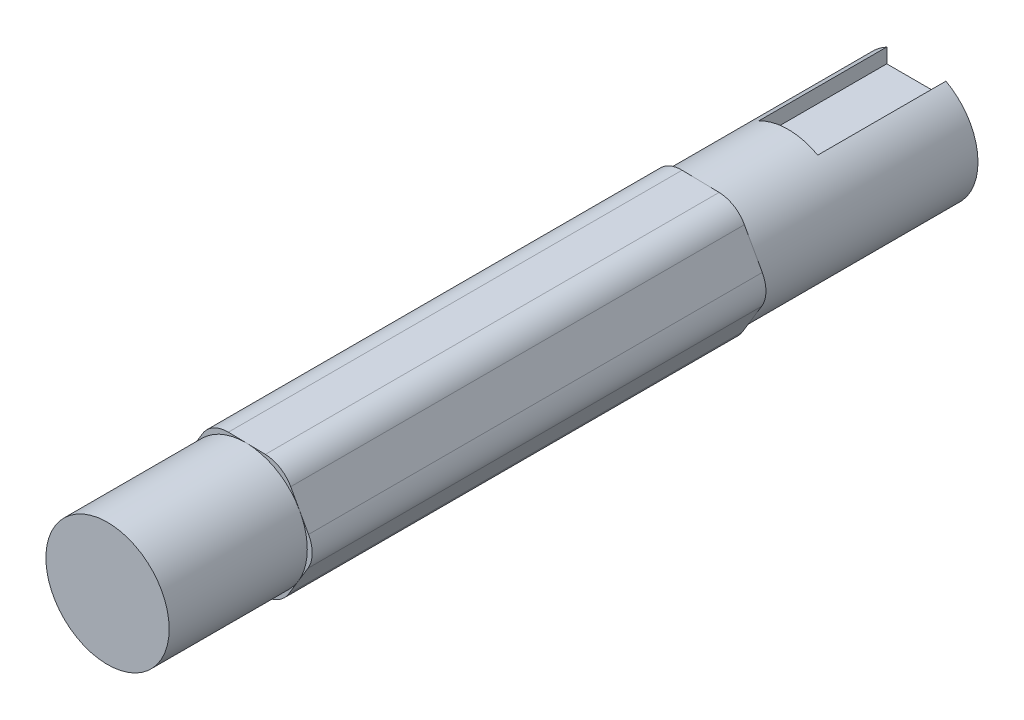
from build123d import *

# Parameters (mm, degrees)
SKETCH1_R                = 6.25
BOSS_EXTRUDE1_DEPTH      = 37
BOSS_EXTRUDE1_DEPTH_BACK = 45
SKETCH4_W                = 6
SKETCH4_H                = 4.5
CUT_EXTRUDE1_DEPTH       = 13
BOSS_EXTRUDE2_DEPTH      = 46
FILLET1_R                = 3


with BuildPart() as part:
    # Sketch1 → Boss-Extrude1 (new body, two sides)
    with BuildSketch(Plane.XY) as boss_extrude1_sk:
        Circle(SKETCH1_R)
    extrude(amount=BOSS_EXTRUDE1_DEPTH)
    extrude(boss_extrude1_sk.sketch, amount=-BOSS_EXTRUDE1_DEPTH_BACK)

    # Sketch4 → Cut-Extrude1 (cut)
    with BuildSketch(Plane(origin=(0, 0, -45), x_dir=(-1, 0, 0), z_dir=(0, 0, -1))):
        with Locations((0, 6.25)):
            Rectangle(SKETCH4_W, SKETCH4_H)
    extrude(amount=-CUT_EXTRUDE1_DEPTH, mode=Mode.SUBTRACT)

    # Sketch5 → Boss-Extrude2 (add)
    with BuildSketch(Plane.XY.offset(-23)):
        Polygon((3.732897661, 6.176472163), (-3.482532969, 6.321020286), (-7.21543063, 0.144548123), (-3.732897661, -6.176472163), (3.482532969, -6.321020286), (7.21543063, -0.144548123), align=None)
    extrude(amount=BOSS_EXTRUDE2_DEPTH)

    # Fillet1
    fillet1_edges = [part.edges().sort_by_distance(p)[0] for p in [
        (7.21543063, -0.144548123, 0),
        (3.732897661, 6.176472163, 0),
        (-3.482532969, 6.321020286, 0),
        (-7.21543063, 0.144548123, 0),
        (-3.732897661, -6.176472163, 0),
        (3.482532969, -6.321020286, 0),
    ]]
    fillet(fillet1_edges, radius=FILLET1_R)


solid = part.part
